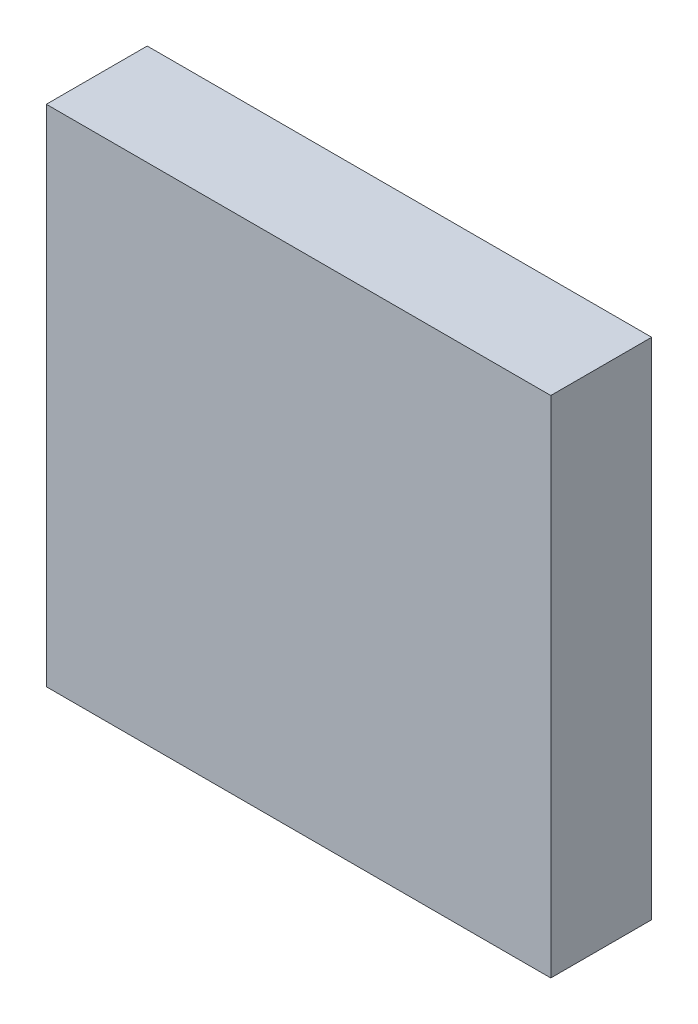
from build123d import *

# Parameters (mm, degrees)
SKETCH2_W           = 30
SKETCH2_H           = 30
SKETCH2_R           = 12.55
BOSS_EXTRUDE1_DEPTH = 5
SKETCH4_W           = 30
SKETCH4_H           = 30
BOSS_EXTRUDE2_DEPTH = 1


with BuildPart() as part:
    # Sketch2 → Boss-Extrude1 (new body)
    with BuildSketch(Plane.XY):
        Rectangle(SKETCH2_W, SKETCH2_H)
        Circle(SKETCH2_R, mode=Mode.SUBTRACT)
    extrude(amount=-BOSS_EXTRUDE1_DEPTH)

    # Sketch4 → Boss-Extrude2 (add)
    with BuildSketch(Plane.XY):
        Rectangle(SKETCH4_W, SKETCH4_H)
    extrude(amount=BOSS_EXTRUDE2_DEPTH)


solid = part.part
